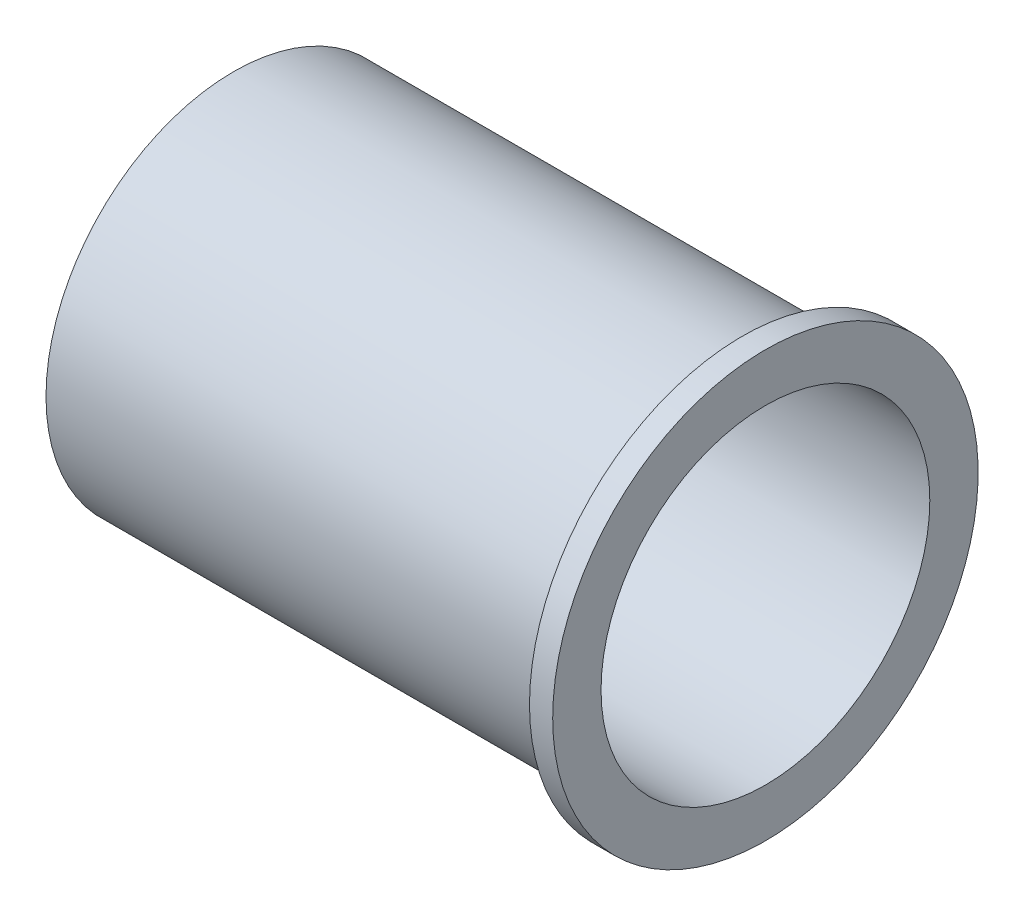
from build123d import *


with BuildPart() as part:
    # Sketch1 → Revolve1 (revolve)
    with BuildSketch(Plane.XY):
        Polygon((-137.5, 42.5), (0, 42.5), (0, 55), (-6, 55), (-6, 48.5), (-137.5, 48.5), align=None)
    revolve(axis=Axis((-94.889937107, 0, 0), (1, 0, 0)))


solid = part.part
